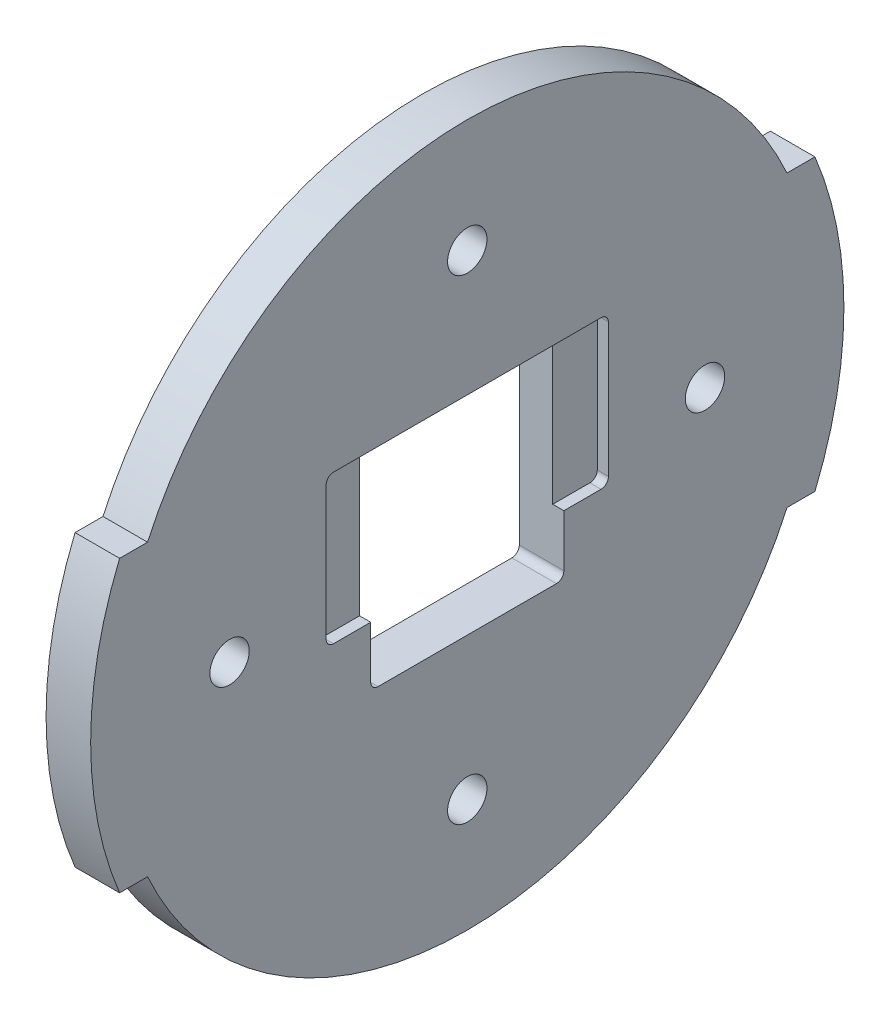
from build123d import *

# Parameters (mm, degrees)
BOSS_EXTRUDE1_DEPTH      = 6
CUT_EXTRUDE1_DEPTH       = 20
M5_CLEARANCE_HOLE1_D     = 5.3
M5_CLEARANCE_HOLE1_DEPTH = 15
M5_CLEARANCE_HOLE1_TIP   = 1.59228064
CUT_EXTRUDE2_DEPTH       = 1.5
FILLET1_R                = 1


with BuildPart() as part:
    # Sketch1 → Boss-Extrude1 (new body)
    with BuildSketch(Plane(origin=(0, 0, 0), x_dir=(0, 0, -1), z_dir=(1, 0, 0))):
        with BuildLine():
            Line((-46.8, 19.5), (-43.038500206, 19.5))
            ThreePointArc((-43.038500206, 19.5), (0, 47.25), (43.038500206, 19.5))
            Line((43.038500206, 19.5), (46.8, 19.5))
            ThreePointArc((46.8, 19.5), (50.7, 0), (46.8, -19.5))
            Line((46.8, -19.5), (43.038500206, -19.5))
            ThreePointArc((43.038500206, -19.5), (0, -47.25), (-43.038500206, -19.5))
            Line((-43.038500206, -19.5), (-46.8, -19.5))
            ThreePointArc((-46.8, -19.5), (-50.7, 0), (-46.8, 19.5))
        make_face()
    extrude(amount=BOSS_EXTRUDE1_DEPTH)

    # Sketch2 → Cut-Extrude1 (cut)
    with BuildSketch(Plane(origin=(6, 0, 0), x_dir=(0, 0, -1), z_dir=(1, 0, 0))):
        with BuildLine():
            ThreePointArc((12, -11.85), (12.707106781, -11.557106781), (13, -10.85))
            Line((13, -10.85), (13, -3.85))
            Line((13, -3.85), (13, 14.15))
            ThreePointArc((13, 14.15), (12.707106781, 14.857106781), (12, 15.15))
            Line((12, 15.15), (-12, 15.15))
            ThreePointArc((-12, 15.15), (-12.707106781, 14.857106781), (-13, 14.15))
            Line((-13, 14.15), (-13, -3.85))
            Line((-13, -3.85), (-13, -10.85))
            ThreePointArc((-13, -10.85), (-12.707106781, -11.557106781), (-12, -11.85))
            Line((-12, -11.85), (12, -11.85))
        make_face()
        with BuildLine():
            Line((-12, -12.85), (12, -12.85))
            ThreePointArc((12, -12.85), (12.707106781, -12.557106781), (13, -11.85))
            Line((13, -11.85), (13, -10.85))
            ThreePointArc((13, -10.85), (12.707106781, -11.557106781), (12, -11.85))
            Line((12, -11.85), (-12, -11.85))
            ThreePointArc((-12, -11.85), (-12.707106781, -11.557106781), (-13, -10.85))
            Line((-13, -10.85), (-13, -11.85))
            ThreePointArc((-13, -11.85), (-12.707106781, -12.557106781), (-12, -12.85))
        make_face()
    extrude(amount=-CUT_EXTRUDE1_DEPTH, mode=Mode.SUBTRACT)

    # M5 Clearance Hole1
    with Locations(Plane.ZY):
        with Locations((-32, 0), (0, 32), (32, 0), (0, -32)):
            Hole(M5_CLEARANCE_HOLE1_D / 2, depth=M5_CLEARANCE_HOLE1_DEPTH)
            with Locations((0, 0, -(M5_CLEARANCE_HOLE1_DEPTH + M5_CLEARANCE_HOLE1_TIP / 2))):  # 118° drill point
                Cone(0, M5_CLEARANCE_HOLE1_D / 2, M5_CLEARANCE_HOLE1_TIP, mode=Mode.SUBTRACT)

    # Sketch16 → Cut-Extrude2 (cut)
    with BuildSketch(Plane(origin=(6, 0, 0), x_dir=(0, 0, -1), z_dir=(1, 0, 0))):
        with BuildLine():
            ThreePointArc((-13, 14.15), (-12.707106781, 14.857106781), (-12, 15.15))
            Line((-12, 15.15), (-19, 15.15))
            Line((-19, 15.15), (-19, -4.85))
            Line((-19, -4.85), (-13, -4.85))
            Line((-13, -4.85), (-13, 14.15))
        make_face()
        with BuildLine():
            Line((0, -4.85), (0, 15.15))
            Line((0, 15.15), (-12, 15.15))
            ThreePointArc((-12, 15.15), (-12.707106781, 14.857106781), (-13, 14.15))
            Line((-13, 14.15), (-13, -4.85))
            Line((-13, -4.85), (0, -4.85))
        make_face()
        with BuildLine():
            ThreePointArc((13, 14.15), (12.707106781, 14.857106781), (12, 15.15))
            Line((12, 15.15), (0, 15.15))
            Line((0, 15.15), (0, -4.85))
            Line((0, -4.85), (13, -4.85))
            Line((13, -4.85), (13, 14.15))
        make_face()
        with BuildLine():
            Line((19, -4.85), (19, 15.15))
            Line((19, 15.15), (12, 15.15))
            ThreePointArc((12, 15.15), (12.707106781, 14.857106781), (13, 14.15))
            Line((13, 14.15), (13, -4.85))
            Line((13, -4.85), (19, -4.85))
        make_face()
    extrude(amount=-CUT_EXTRUDE2_DEPTH, mode=Mode.SUBTRACT)

    # Fillet1
    fillet1_edges = [part.edges().sort_by_distance(p)[0] for p in [
        (5.25, 15.15, 19),
        (5.25, -4.85, -19),
        (5.25, -4.85, 19),
        (5.25, 15.15, -19),
    ]]
    fillet(fillet1_edges, radius=FILLET1_R)


solid = part.part
